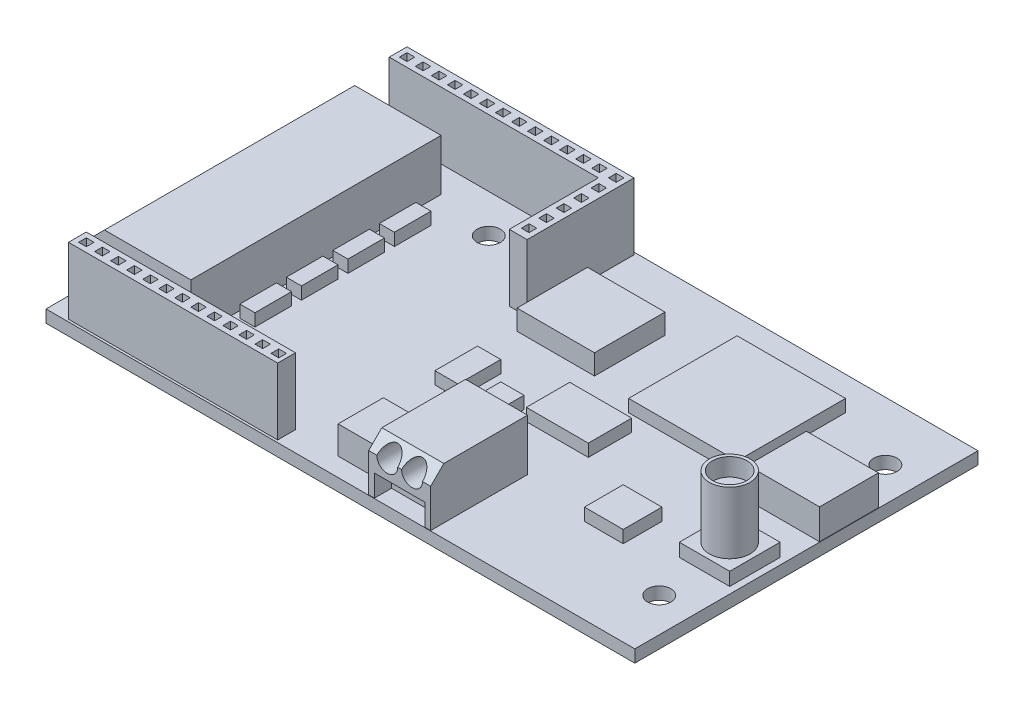
from build123d import *

# Parameters (mm, degrees)
SKETCH1_W            = 76
SKETCH1_H            = 44.3
SKETCH1_R            = 1.5
BOSS_EXTRUDE1_DEPTH  = 1.6
SKETCH2_W            = 12.65
SKETCH2_H            = 32.3
BOSS_EXTRUDE2_DEPTH  = 6.6
CHAMFER1_SIZE        = 1.5
SKETCH3_W            = 6.5
SKETCH3_H            = 2.7
CUT_EXTRUDE1_DEPTH   = 2.5
SKETCH4_R            = 1.35
CUT_EXTRUDE2_DEPTH   = 12
LPATTERN1_COUNT      = 4
LPATTERN1_PITCH      = 8.2
SKETCH5_W            = 1
SKETCH5_H            = 1
SKETCH5_W_2          = 27
SKETCH5_H_2          = 2.3
BOSS_EXTRUDE3_DEPTH  = 8.6
SKETCH6_W            = 10
SKETCH6_H            = 9.1
BOSS_EXTRUDE4_DEPTH  = 2.6
SKETCH7_W            = 8
SKETCH7_H            = 12.5
BOSS_EXTRUDE5_DEPTH  = 6.65
CHAMFER2_SIZE        = 1.7
SKETCH8_W            = 6.5
SKETCH8_H            = 2.8
CUT_EXTRUDE3_DEPTH   = 2.2
SKETCH9_R            = 1.35
CUT_EXTRUDE4_DEPTH   = 12
SKETCH10_W           = 1.94893089
SKETCH10_H           = 4.722409465
SKETCH10_W_2         = 14
SKETCH10_H_2         = 14
SKETCH10_W_3         = 8
SKETCH10_H_3         = 5.6
SKETCH10_W_4         = 5
SKETCH10_H_4         = 5
SKETCH10_W_5         = 3
SKETCH10_H_5         = 3
SKETCH10_H_6         = 5.5
BOSS_EXTRUDE6_DEPTH  = 1.6
SKETCH11_W           = 9.3
SKETCH11_H           = 7.6
BOSS_EXTRUDE7_DEPTH  = 3.9
SKETCH12_W           = 6.5
SKETCH12_H           = 6.5
BOSS_EXTRUDE8_DEPTH  = 1.7
SKETCH13_R           = 2.625
BOSS_EXTRUDE9_DEPTH  = 8
SKETCH14_R           = 2.225
CUT_EXTRUDE5_DEPTH   = 2.3
SKETCH15_W           = 5.8
SKETCH15_H           = 5.85
BOSS_EXTRUDE10_DEPTH = 3.6


with BuildPart() as part:
    # Sketch1 → Boss-Extrude1 (new body)
    with BuildSketch(Plane(origin=(0, 0, 0), x_dir=(1, 0, 0), z_dir=(0, 1, 0))):
        with Locations((38, 22.15)):
            Rectangle(SKETCH1_W, SKETCH1_H)
        with Locations(Location((20.4, 36.75, 0), (0, 0, 270))):  # turned: the seam where the file's is
            Circle(SKETCH1_R, mode=Mode.SUBTRACT)
        with Locations(Location((71.6, 36.75, 0), (0, 0, 270))):  # turned: the seam where the file's is
            Circle(SKETCH1_R, mode=Mode.SUBTRACT)
        with Locations(Location((20.4, 7.55, 0), (0, 0, 270))):  # turned: the seam where the file's is
            Circle(SKETCH1_R, mode=Mode.SUBTRACT)
        with Locations(Location((71.6, 7.55, 0), (0, 0, 270))):  # turned: the seam where the file's is
            Circle(SKETCH1_R, mode=Mode.SUBTRACT)
    extrude(amount=BOSS_EXTRUDE1_DEPTH)

    # Sketch2 → Boss-Extrude2 (add)
    with BuildSketch(Plane(origin=(0, 1.6, 0), x_dir=(1, 0, 0), z_dir=(0, 1, 0))):
        with Locations((6.375, 22.15)):
            Rectangle(SKETCH2_W, SKETCH2_H)
    extrude(amount=BOSS_EXTRUDE2_DEPTH)

    # Chamfer1
    chamfer1_edges = [part.edges().sort_by_distance(p)[0] for p in [
        (0.05, 8.2, -22.15),
    ]]
    chamfer(chamfer1_edges, length=CHAMFER1_SIZE)

    # Sketch3 → Cut-Extrude1 (cut)
    with BuildSketch(Plane.ZY.offset(-0.05)):
        with Locations((-34.45, 2.95)):
            Rectangle(SKETCH3_W, SKETCH3_H)
        with Locations((-26.25, 2.95)):
            Rectangle(SKETCH3_W, SKETCH3_H)
        with Locations((-18.05, 2.95)):
            Rectangle(SKETCH3_W, SKETCH3_H)
        with Locations((-9.85, 2.95)):
            Rectangle(SKETCH3_W, SKETCH3_H)
    extrude(amount=-CUT_EXTRUDE1_DEPTH, mode=Mode.SUBTRACT)

    # Sketch4 → Cut-Extrude2 (cut)
    with BuildSketch(Plane.ZY.offset(-0.05)):
        with Locations((-36.05, 6.7)):
            Circle(SKETCH4_R)
        with Locations((-32.85, 6.7)):
            Circle(SKETCH4_R)
    cut_extrude2 = extrude(amount=-CUT_EXTRUDE2_DEPTH, mode=Mode.SUBTRACT)

    # LPattern1: Cut-Extrude2 ×4
    with Locations(*[(0, 0, i * LPATTERN1_PITCH) for i in range(1, LPATTERN1_COUNT)]):
        add(cut_extrude2, mode=Mode.SUBTRACT)

    # Sketch5 → Boss-Extrude3 (add)
    with BuildSketch(Plane(origin=(0, 1.6, 0), x_dir=(1, 0, 0), z_dir=(0, 1, 0))):
        Polygon((2.6, 44), (31.9, 44), (31.9, 30.2), (29.6, 30.2), (29.6, 41.7), (2.6, 41.7), align=None)
        with Locations((5.82, 42.85)):
            Rectangle(SKETCH5_W, SKETCH5_H, mode=Mode.SUBTRACT)
        with Locations((3.75, 42.85)):
            Rectangle(SKETCH5_W, SKETCH5_H, mode=Mode.SUBTRACT)
        with Locations((7.89, 42.85)):
            Rectangle(SKETCH5_W, SKETCH5_H, mode=Mode.SUBTRACT)
        with Locations((9.96, 42.85)):
            Rectangle(SKETCH5_W, SKETCH5_H, mode=Mode.SUBTRACT)
        with Locations((12.03, 42.85)):
            Rectangle(SKETCH5_W, SKETCH5_H, mode=Mode.SUBTRACT)
        with Locations((14.1, 42.85)):
            Rectangle(SKETCH5_W, SKETCH5_H, mode=Mode.SUBTRACT)
        with Locations((16.17, 42.85)):
            Rectangle(SKETCH5_W, SKETCH5_H, mode=Mode.SUBTRACT)
        with Locations((18.24, 42.85)):
            Rectangle(SKETCH5_W, SKETCH5_H, mode=Mode.SUBTRACT)
        with Locations((20.31, 42.85)):
            Rectangle(SKETCH5_W, SKETCH5_H, mode=Mode.SUBTRACT)
        with Locations((22.38, 42.85)):
            Rectangle(SKETCH5_W, SKETCH5_H, mode=Mode.SUBTRACT)
        with Locations((24.45, 42.85)):
            Rectangle(SKETCH5_W, SKETCH5_H, mode=Mode.SUBTRACT)
        with Locations((26.52, 42.85)):
            Rectangle(SKETCH5_W, SKETCH5_H, mode=Mode.SUBTRACT)
        with Locations((28.59, 42.85)):
            Rectangle(SKETCH5_W, SKETCH5_H, mode=Mode.SUBTRACT)
        with Locations((30.75, 40.6)):
            Rectangle(SKETCH5_W, SKETCH5_H, mode=Mode.SUBTRACT)
        with Locations((30.75, 42.85)):
            Rectangle(SKETCH5_W, SKETCH5_H, mode=Mode.SUBTRACT)
        with Locations((30.75, 38.35)):
            Rectangle(SKETCH5_W, SKETCH5_H, mode=Mode.SUBTRACT)
        with Locations((30.75, 36.1)):
            Rectangle(SKETCH5_W, SKETCH5_H, mode=Mode.SUBTRACT)
        with Locations((30.75, 33.85)):
            Rectangle(SKETCH5_W, SKETCH5_H, mode=Mode.SUBTRACT)
        with Locations((30.75, 31.6)):
            Rectangle(SKETCH5_W, SKETCH5_H, mode=Mode.SUBTRACT)
        with Locations((16.1, 1.45)):
            Rectangle(SKETCH5_W_2, SKETCH5_H_2)
        with Locations((5.82, 1.45)):
            Rectangle(SKETCH5_W, SKETCH5_H, mode=Mode.SUBTRACT)
        with Locations((7.89, 1.45)):
            Rectangle(SKETCH5_W, SKETCH5_H, mode=Mode.SUBTRACT)
        with Locations((9.96, 1.45)):
            Rectangle(SKETCH5_W, SKETCH5_H, mode=Mode.SUBTRACT)
        with Locations((12.03, 1.45)):
            Rectangle(SKETCH5_W, SKETCH5_H, mode=Mode.SUBTRACT)
        with Locations((14.1, 1.45)):
            Rectangle(SKETCH5_W, SKETCH5_H, mode=Mode.SUBTRACT)
        with Locations((16.17, 1.45)):
            Rectangle(SKETCH5_W, SKETCH5_H, mode=Mode.SUBTRACT)
        with Locations((18.24, 1.45)):
            Rectangle(SKETCH5_W, SKETCH5_H, mode=Mode.SUBTRACT)
        with Locations((20.31, 1.45)):
            Rectangle(SKETCH5_W, SKETCH5_H, mode=Mode.SUBTRACT)
        with Locations((22.38, 1.45)):
            Rectangle(SKETCH5_W, SKETCH5_H, mode=Mode.SUBTRACT)
        with Locations((24.45, 1.45)):
            Rectangle(SKETCH5_W, SKETCH5_H, mode=Mode.SUBTRACT)
        with Locations((26.52, 1.45)):
            Rectangle(SKETCH5_W, SKETCH5_H, mode=Mode.SUBTRACT)
        with Locations((28.59, 1.45)):
            Rectangle(SKETCH5_W, SKETCH5_H, mode=Mode.SUBTRACT)
        with Locations((3.75, 1.45)):
            Rectangle(SKETCH5_W, SKETCH5_H, mode=Mode.SUBTRACT)
    extrude(amount=BOSS_EXTRUDE3_DEPTH)

    # Sketch6 → Boss-Extrude4 (add)
    with BuildSketch(Plane(origin=(0, 1.6, 0), x_dir=(1, 0, 0), z_dir=(0, 1, 0))):
        with Locations((37.9, 32.45)):
            Rectangle(SKETCH6_W, SKETCH6_H)
    extrude(amount=BOSS_EXTRUDE4_DEPTH)

    # Sketch7 → Boss-Extrude5 (add)
    with BuildSketch(Plane(origin=(0, 1.6, 0), x_dir=(1, 0, 0), z_dir=(0, 1, 0))):
        with Locations((45.6, 6.3)):
            Rectangle(SKETCH7_W, SKETCH7_H)
    extrude(amount=BOSS_EXTRUDE5_DEPTH)

    # Chamfer2
    chamfer2_edges = [part.edges().sort_by_distance(p)[0] for p in [
        (45.6, 8.25, -0.05),
    ]]
    chamfer(chamfer2_edges, length=CHAMFER2_SIZE)

    # Sketch8 → Cut-Extrude3 (cut)
    with BuildSketch(Plane.XY.offset(-0.05)):
        with Locations((45.6, 3)):
            Rectangle(SKETCH8_W, SKETCH8_H)
    extrude(amount=-CUT_EXTRUDE3_DEPTH, mode=Mode.SUBTRACT)

    # Sketch9 → Cut-Extrude4 (cut)
    with BuildSketch(Plane.XY.offset(-0.05)):
        with Locations((44, 6.55)):
            Circle(SKETCH9_R)
        with Locations((47.2, 6.55)):
            Circle(SKETCH9_R)
    extrude(amount=-CUT_EXTRUDE4_DEPTH, mode=Mode.SUBTRACT)

    # Sketch10 → Boss-Extrude6 (add)
    with BuildSketch(Plane(origin=(0, 1.6, 0), x_dir=(1, 0, 0), z_dir=(0, 1, 0))):
        with Locations((14.537870434, 25.819695572)):
            Rectangle(SKETCH10_W, SKETCH10_H)
        with Locations((56.2, 33)):
            Rectangle(SKETCH10_W_2, SKETCH10_H_2)
        with Locations((47.6, 21.2)):
            Rectangle(SKETCH10_W_3, SKETCH10_H_3)
        with Locations((61, 13.5)):
            Rectangle(SKETCH10_W_4, SKETCH10_H_4)
        with Locations((40.6, 18.1)):
            Rectangle(SKETCH10_W_5, SKETCH10_H_5)
        with Locations((35.1, 19.35)):
            Rectangle(SKETCH10_W_5, SKETCH10_H_6)
        with Locations((14.537870434, 31.819695572)):
            Rectangle(SKETCH10_W, SKETCH10_H)
        with Locations((14.537870434, 19.819695571)):
            Rectangle(SKETCH10_W, SKETCH10_H)
        with Locations((14.537870434, 13.819695572)):
            Rectangle(SKETCH10_W, SKETCH10_H)
    extrude(amount=BOSS_EXTRUDE6_DEPTH)

    # Sketch11 → Boss-Extrude7 (add)
    with BuildSketch(Plane(origin=(0, 1.6, 0), x_dir=(1, 0, 0), z_dir=(0, 1, 0))):
        with Locations((71.3, 27.7)):
            Rectangle(SKETCH11_W, SKETCH11_H)
    extrude(amount=BOSS_EXTRUDE7_DEPTH)

    # Sketch12 → Boss-Extrude8 (add)
    with BuildSketch(Plane(origin=(0, 1.6, 0), x_dir=(1, 0, 0), z_dir=(0, 1, 0))):
        with Locations((71.9, 16.35)):
            Rectangle(SKETCH12_W, SKETCH12_H)
    extrude(amount=BOSS_EXTRUDE8_DEPTH)

    # Sketch13 → Boss-Extrude9 (add)
    with BuildSketch(Plane(origin=(0, 3.3, 0), x_dir=(1, 0, 0), z_dir=(0, 1, 0))):
        with Locations(Location((71.9, 16.35, 0), (0, 0, 270))):  # turned: the seam where the file's is
            Circle(SKETCH13_R)
    extrude(amount=BOSS_EXTRUDE9_DEPTH)

    # Sketch14 → Cut-Extrude5 (cut)
    with BuildSketch(Plane(origin=(0, 11.3, 0), x_dir=(1, 0, 0), z_dir=(0, 1, 0))):
        with Locations(Location((71.9, 16.35, 0), (0, 0, 270))):  # turned: the seam where the file's is
            Circle(SKETCH14_R)
    extrude(amount=-CUT_EXTRUDE5_DEPTH, mode=Mode.SUBTRACT)

    # Sketch15 → Boss-Extrude10 (add)
    with BuildSketch(Plane(origin=(0, 1.6, 0), x_dir=(1, 0, 0), z_dir=(0, 1, 0))):
        with Locations((38.2, 5.325)):
            Rectangle(SKETCH15_W, SKETCH15_H)
    extrude(amount=BOSS_EXTRUDE10_DEPTH)


solid = part.part
